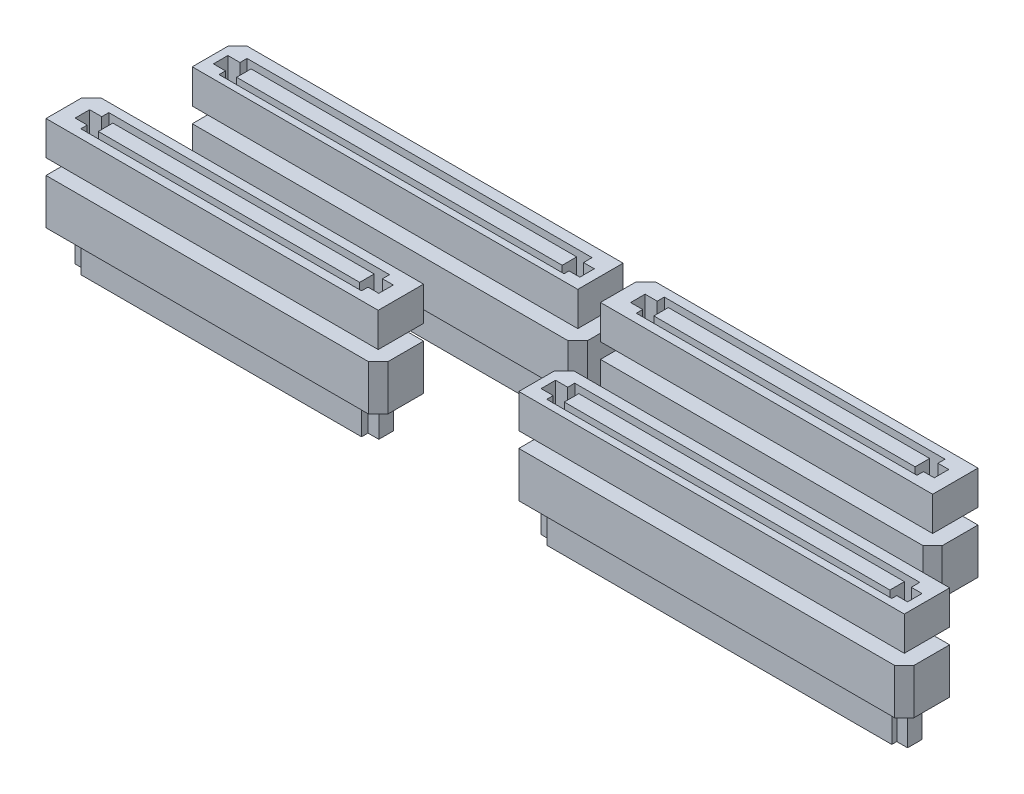
from build123d import *

# Parameters (mm, degrees)
SV_DEPTH           = 3.75
SV_2_DEPTH         = 3.75
SV_3_DEPTH         = 3.75
SV_4_DEPTH         = 3.75
SKETCH3_W          = 28.811718275
SKETCH3_H          = 1.597828601
SKETCH3_W_2        = 35.897762959
SKETCH3_W_3        = 35.897762958
CUT_EXTRUDE1_DEPTH = 3.5
SV4_A_DEPTH        = 5
SV4_A_2_DEPTH      = 5
SV4_A_3_DEPTH      = 5
SV4_A_4_DEPTH      = 5
SKETCH7_W          = 35.897762958
SKETCH7_H          = 1.597828601
SKETCH7_W_2        = 28.811718275
SKETCH7_W_3        = 35.897762959
SV4_B_DEPTH        = 3.5


with BuildPart() as part:
    # Sketch1 → SV (new body)
    with BuildSketch(Plane(origin=(0, 0, 0), x_dir=(1, 0, 0), z_dir=(0, 1, 0))):
        Polygon((55.811, 9.5), (97.25, 9.5), (97.25, 5.56), (97.25, 4.5), (96.19, 4.5), (54.75, 4.5), (54.75, 8.439), align=None)
    extrude(amount=SV_DEPTH)


with BuildPart() as body_2:
    # Sketch1 → SV 2 (new body)
    with BuildSketch(Plane(origin=(0, 0, 0), x_dir=(1, 0, 0), z_dir=(0, 1, 0))):
        Polygon((3.686, 9.5), (39.25, 9.5), (39.25, 5.555), (39.25, 4.5), (38.195, 4.5), (2.625, 4.5), (2.625, 8.439), align=None)
    extrude(amount=SV_2_DEPTH)


with BuildPart() as body_3:
    # Sketch1 → SV 3 (new body)
    with BuildSketch(Plane(origin=(0, 0, 0), x_dir=(1, 0, 0), z_dir=(0, 1, 0))):
        Polygon((51.811, 22.5), (87.375, 22.5), (87.375, 18.555), (87.375, 17.5), (86.32, 17.5), (50.75, 17.5), (50.75, 21.439), align=None)
    extrude(amount=SV_3_DEPTH)


with BuildPart() as body_4:
    # Sketch1 → SV 4 (new body)
    with BuildSketch(Plane(origin=(0, 0, 0), x_dir=(1, 0, 0), z_dir=(0, 1, 0))):
        Polygon((6.811, 22.5), (48.25, 22.5), (48.25, 18.56), (48.25, 17.5), (47.19, 17.5), (5.75, 17.5), (5.75, 21.439), align=None)
    extrude(amount=SV_4_DEPTH)


with BuildPart() as cut_extrude1_tool:
    # Sketch3 → Cut-Extrude1 (new body)
    with BuildSketch(Plane(origin=(0, 3.75, 0), x_dir=(1, 0, 0), z_dir=(0, 1, 0))):
        Polygon((4.189336253, 7.745735487), (5.524337048, 7.745735487), (5.524337048, 8.524173538), (36.475691419, 8.524173538), (36.475691419, 7.745735487), (37.666991912, 7.745735487), (37.666991912, 6.147906886), (36.475691419, 6.147906886), (36.475691419, 5.438560322), (5.524337048, 5.438560322), (5.524337048, 6.147906886), (4.189336253, 6.147906886), align=None)
        with Locations((21.152985591, 6.946821187)):
            Rectangle(SKETCH3_W, SKETCH3_H, mode=Mode.SUBTRACT)
        Polygon((52.421116037, 20.753597434), (53.756116831, 20.753597434), (53.756116831, 21.532035485), (84.707471203, 21.532035485), (84.707471203, 20.753597434), (85.898771695, 20.753597434), (85.898771695, 19.155768833), (84.707471203, 19.155768833), (84.707471203, 18.446422269), (53.756116831, 18.446422269), (53.756116831, 19.155768833), (52.421116037, 19.155768833), align=None)
        with Locations((69.384765375, 19.954683133)):
            Rectangle(SKETCH3_W, SKETCH3_H, mode=Mode.SUBTRACT)
        Polygon((55.705906871, 7.599031898), (57.040907666, 7.599031898), (57.040907666, 8.377469948), (95.07830672, 8.377469948), (95.07830672, 7.437727621), (96.269607213, 7.437727621), (96.269607213, 5.83989902), (95.07830672, 5.83989902), (95.07830672, 5.291856733), (57.040907666, 5.291856733), (57.040907666, 6.001203297), (55.705906871, 6.001203297), align=None)
        with Locations((76.21257855, 6.800117597)):
            Rectangle(SKETCH3_W_2, SKETCH3_H, mode=Mode.SUBTRACT)
        Polygon((6.636601859, 20.53972103), (7.971602653, 20.53972103), (7.971602653, 21.318159081), (46.009001708, 21.318159081), (46.009001708, 20.378416754), (47.2003022, 20.378416754), (47.2003022, 18.780588153), (46.009001708, 18.780588153), (46.009001708, 18.232545866), (7.971602653, 18.232545866), (7.971602653, 18.941892429), (6.636601859, 18.941892429), align=None)
        with Locations((27.143273538, 19.74080673)):
            Rectangle(SKETCH3_W_3, SKETCH3_H, mode=Mode.SUBTRACT)
    extrude(amount=-CUT_EXTRUDE1_DEPTH)


with BuildPart() as part_1:
    add(part.part)

    # Cut-Extrude1: cut by cut_extrude1_tool
    add(cut_extrude1_tool.part, mode=Mode.SUBTRACT)


with BuildPart() as body_2_1:
    add(body_2.part)

    # Cut-Extrude1: cut by cut_extrude1_tool
    add(cut_extrude1_tool.part, mode=Mode.SUBTRACT)


with BuildPart() as body_3_1:
    add(body_3.part)

    # Cut-Extrude1: cut by cut_extrude1_tool
    add(cut_extrude1_tool.part, mode=Mode.SUBTRACT)


with BuildPart() as body_4_1:
    add(body_4.part)

    # Cut-Extrude1: cut by cut_extrude1_tool
    add(cut_extrude1_tool.part, mode=Mode.SUBTRACT)


with BuildPart() as body_5:
    # Sketch6 → SV4(a) (new body)
    with BuildSketch(Plane(origin=(0, -1.68656, 0), x_dir=(1, 0, 0), z_dir=(0, 1, 0))):
        Polygon((2.625, 4.5), (38.195, 4.5), (39.25, 5.555), (39.25, 9.5), (3.685, 9.5), (2.625, 9.5), (2.625, 8.44), align=None)
    extrude(amount=-SV4_A_DEPTH)



with BuildPart() as body_6:
    # Sketch6 → SV4_a 2 (new body)
    with BuildSketch(Plane(origin=(0, -1.68656, 0), x_dir=(1, 0, 0), z_dir=(0, 1, 0))):
        Polygon((48.25, 18.56191605), (47.18808395, 17.5), (5.75, 17.5), (5.75, 21.44), (5.75, 22.5), (6.81, 22.5), (48.25, 22.5), align=None)
    extrude(amount=-SV4_A_2_DEPTH)


with BuildPart() as body_7:
    # Sketch6 → SV4_a 3 (new body)
    with BuildSketch(Plane(origin=(0, -1.68656, 0), x_dir=(1, 0, 0), z_dir=(0, 1, 0))):
        Polygon((54.75, 4.5), (96.19, 4.5), (97.25, 5.56), (97.25, 9.5), (55.81, 9.5), (54.75, 9.5), (54.75, 8.44), align=None)
    extrude(amount=-SV4_A_3_DEPTH)


with BuildPart() as body_8:
    # Sketch6 → SV4_a 4 (new body)
    with BuildSketch(Plane(origin=(0, -1.68656, 0), x_dir=(1, 0, 0), z_dir=(0, 1, 0))):
        Polygon((50.75, 17.5), (86.32, 17.5), (87.375, 18.555), (87.375, 22.5), (51.805, 22.5), (50.75, 22.5), (50.75, 21.445), align=None)
    extrude(amount=-SV4_A_4_DEPTH)


with BuildPart() as body_5_1:
    add(body_5.part)

    add(body_6.part)  # SV4(b) merges body 6

    add(body_7.part)  # SV4(b) merges body 7

    add(body_8.part)  # SV4(b) merges body 8
    # Sketch7 → SV4(b) (add)
    with BuildSketch(Plane.XZ.offset(6.68656)):
        Polygon((7.971602653, -21.318159081), (7.971602653, -20.53972103), (6.636601859, -20.53972103), (6.636601859, -18.941892429), (7.971602653, -18.941892429), (7.971602653, -18.232545866), (46.009001708, -18.232545866), (46.009001708, -18.780588153), (47.2003022, -18.780588153), (47.2003022, -20.378416754), (46.009001708, -20.378416754), (46.009001708, -21.318159081), align=None)
        with Locations((27.143273538, -19.74080673)):
            Rectangle(SKETCH7_W, SKETCH7_H, mode=Mode.SUBTRACT)
        Polygon((53.756116831, -21.532035485), (84.707471203, -21.532035485), (84.707471203, -20.753597434), (85.898771695, -20.753597434), (85.898771695, -19.155768833), (84.707471203, -19.155768833), (84.707471203, -18.446422269), (53.756116831, -18.446422269), (53.756116831, -19.155768833), (52.421116037, -19.155768833), (52.421116037, -20.753597434), (53.756116831, -20.753597434), align=None)
        with Locations((69.384765375, -19.954683133)):
            Rectangle(SKETCH7_W_2, SKETCH7_H, mode=Mode.SUBTRACT)
        Polygon((57.040907666, -8.377469948), (57.040907666, -7.599031898), (55.705906871, -7.599031898), (55.705906871, -6.001203297), (57.040907666, -6.001203297), (57.040907666, -5.291856733), (95.07830672, -5.291856733), (95.07830672, -5.83989902), (96.269607213, -5.83989902), (96.269607213, -7.437727621), (95.07830672, -7.437727621), (95.07830672, -8.377469948), align=None)
        with Locations((76.21257855, -6.800117597)):
            Rectangle(SKETCH7_W_3, SKETCH7_H, mode=Mode.SUBTRACT)
        Polygon((4.189336253, -6.147906886), (5.524337048, -6.147906886), (5.524337048, -5.438560322), (36.475691419, -5.438560322), (36.475691419, -6.147906886), (37.666991912, -6.147906886), (37.666991912, -7.745735487), (36.475691419, -7.745735487), (36.475691419, -8.524173538), (5.524337048, -8.524173538), (5.524337048, -7.745735487), (4.189336253, -7.745735487), align=None)
        with Locations((21.152985591, -6.946821187)):
            Rectangle(SKETCH7_W_2, SKETCH7_H, mode=Mode.SUBTRACT)
    extrude(amount=SV4_B_DEPTH)


solid = Compound([part_1.part, body_2_1.part, body_3_1.part, body_4_1.part, body_5_1.part])
